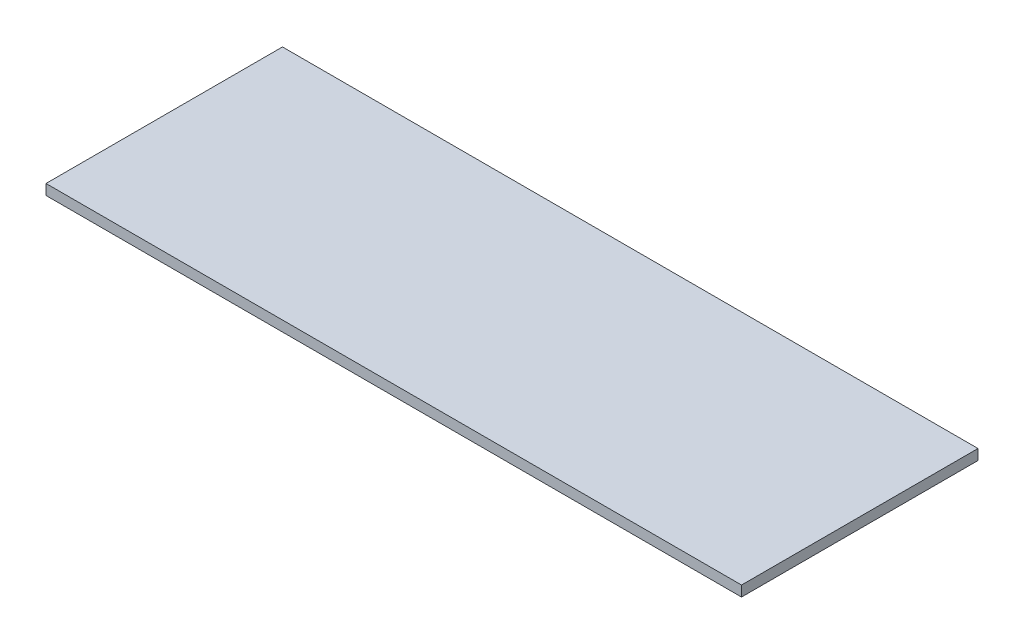
from build123d import *

# Parameters (mm, degrees)
SKETCH1_W           = 254
SKETCH1_H           = 86.36
BOSS_EXTRUDE1_DEPTH = 3.81


with BuildPart() as part:
    # Sketch1 → Boss-Extrude1 (new body)
    with BuildSketch(Plane(origin=(0, 0, 0), x_dir=(1, 0, 0), z_dir=(0, 1, 0))):
        with Locations((3.916299559, 17.802378855)):
            Rectangle(SKETCH1_W, SKETCH1_H)
    extrude(amount=BOSS_EXTRUDE1_DEPTH)


solid = part.part
